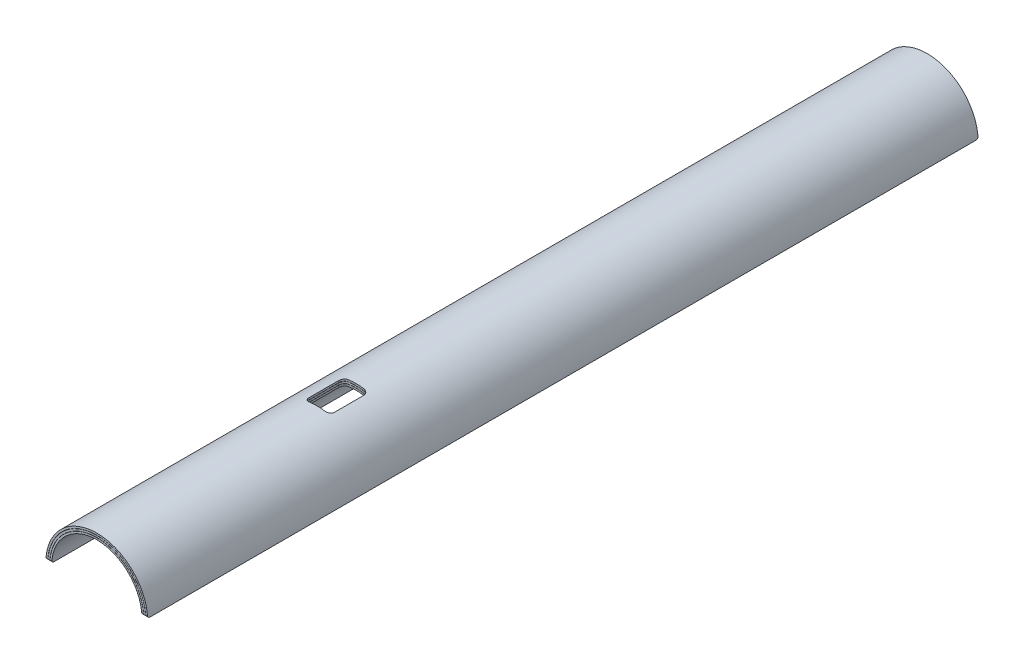
from build123d import *

# Parameters (mm, degrees)
EXTRUDE_THIN1_DEPTH = 524
EXTRUDE_THIN2_DEPTH = 524
EXTRUDE_THIN3_DEPTH = 524
FILLET1_R           = 3
FILLET2_R           = 3
FILLET3_R           = 3
CUT_EXTRUDE1_DEPTH  = 65.3400001


with BuildPart() as part:
    # Sketch1 → Extrude-Thin1 (new body, symmetric)
    with BuildSketch(Plane.XY):
        with BuildLine():
            ThreePointArc((56.920997883, 3), (0, 57), (-56.920997883, 3))
            Line((-56.920997883, 3), (-59.217810078, 3.121052632))
            ThreePointArc((-59.217810078, 3.121052632), (0, 59.3), (59.217810078, 3.121052632))
            Line((59.217810078, 3.121052632), (56.920997883, 3))
        make_face()
    extrude(amount=EXTRUDE_THIN1_DEPTH, both=True)

    # Fillet3
    fillet3_edges = [part.edges().sort_by_distance(p)[0] for p in [
        (58.069403981, 3.060526316, 524),
        (58.069403981, 3.060526316, -524),
        (-58.069403981, 3.060526316, -524),
        (-58.069403981, 3.060526316, 524),
    ]]
    fillet(fillet3_edges, radius=FILLET3_R)


with BuildPart() as body_2:
    # Sketch2 → Extrude-Thin2 (new body, symmetric)
    with BuildSketch(Plane.XY):
        with BuildLine():
            ThreePointArc((59.444347082, 3), (0, 59.52), (-59.444347082, 3))
            Line((-59.444347082, 3), (-61.741423666, 3.115927419))
            ThreePointArc((-61.741423666, 3.115927419), (0, 61.82), (61.741423666, 3.115927419))
            Line((61.741423666, 3.115927419), (59.444347082, 3))
        make_face()
    extrude(amount=EXTRUDE_THIN2_DEPTH, both=True)

    # Fillet2
    fillet2_edges = [body_2.edges().sort_by_distance(p)[0] for p in [
        (60.592885374, 3.05796371, 524),
        (60.592885374, 3.05796371, -524),
        (-60.592885374, 3.05796371, -524),
        (-60.592885374, 3.05796371, 524),
    ]]
    fillet(fillet2_edges, radius=FILLET2_R)


with BuildPart() as body_3:
    # Sketch3 → Extrude-Thin3 (new body, symmetric)
    with BuildSketch(Plane.XY):
        with BuildLine():
            ThreePointArc((61.9674237, 3), (0, 62.04), (-61.9674237, 3))
            Line((-61.9674237, 3), (-64.264733089, 3.111218569))
            ThreePointArc((-64.264733089, 3.111218569), (0, 64.34), (64.264733089, 3.111218569))
            Line((64.264733089, 3.111218569), (61.9674237, 3))
        make_face()
    extrude(amount=EXTRUDE_THIN3_DEPTH, both=True)

    # Fillet1
    fillet1_edges = [body_3.edges().sort_by_distance(p)[0] for p in [
        (63.116078395, 3.055609284, 524),
        (63.116078395, 3.055609284, -524),
        (-63.116078395, 3.055609284, -524),
        (-63.116078395, 3.055609284, 524),
    ]]
    fillet(fillet1_edges, radius=FILLET1_R)


with BuildPart() as cut_extrude1_tool:
    # Sketch4 → Cut-Extrude1 (new body, through all)
    with BuildSketch(Plane(origin=(0, 0, 0), x_dir=(1, 0, 0), z_dir=(0, 1, 0))):
        with BuildLine():
            Line((9.998413649, -246), (-9.998413649, -246))
            ThreePointArc((-9.998413649, -246), (-14.242176056, -244.242176056), (-16, -239.998413649))
            Line((-16, -239.998413649), (-16, -203.001586351))
            ThreePointArc((-16, -203.001586351), (-14.242176056, -198.757823944), (-9.998413649, -197))
            Line((-9.998413649, -197), (9.998413649, -197))
            ThreePointArc((9.998413649, -197), (14.242176056, -198.757823944), (16, -203.001586351))
            Line((16, -203.001586351), (16, -239.998413649))
            ThreePointArc((16, -239.998413649), (14.242176056, -244.242176056), (9.998413649, -246))
        make_face()
    extrude(amount=CUT_EXTRUDE1_DEPTH)


with BuildPart() as part_1:
    add(part.part)

    # Cut-Extrude1: cut by cut_extrude1_tool
    add(cut_extrude1_tool.part, mode=Mode.SUBTRACT)


with BuildPart() as body_2_1:
    add(body_2.part)

    # Cut-Extrude1: cut by cut_extrude1_tool
    add(cut_extrude1_tool.part, mode=Mode.SUBTRACT)


with BuildPart() as body_3_1:
    add(body_3.part)

    # Cut-Extrude1: cut by cut_extrude1_tool
    add(cut_extrude1_tool.part, mode=Mode.SUBTRACT)


solid = Compound([part_1.part, body_2_1.part, body_3_1.part])
